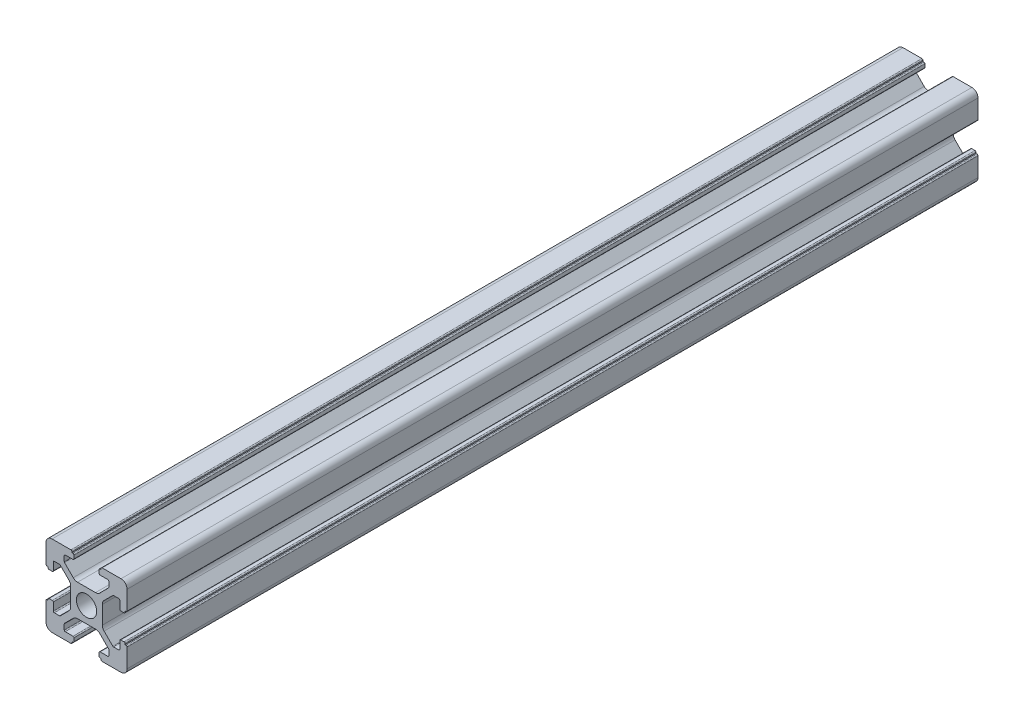
from build123d import *

# Parameters (mm, degrees)
SKETCH_1_R         = 2.5
EXTRUDE_1_DEPTH    = 1220
SKETCH1_R          = 16.771487081
CUT_EXTRUDE1_DEPTH = 1011


with BuildPart() as part:
    # 草图1 → 凸台-拉伸1 (new body)
    with BuildSketch(Plane.XY):
        with BuildLine():
            Line((-8.502261885, -10.002261885), (-3.85, -10.002261885))
            ThreePointArc((-3.85, -10.002261885), (-3.673223305, -9.929038581), (-3.6, -9.752261885))
            Line((-3.6, -9.752261885), (-3.6, -9.502261885))
            Line((-3.6, -9.502261885), (-3.35, -9.502261885))
            ThreePointArc((-3.35, -9.502261885), (-3.173223305, -9.429038581), (-3.1, -9.252261885))
            Line((-3.1, -9.252261885), (-3.1, -8.45))
            ThreePointArc((-3.1, -8.45), (-3.173223305, -8.273223305), (-3.35, -8.2))
            Line((-3.35, -8.2), (-5.25, -8.2))
            ThreePointArc((-5.25, -8.2), (-5.426776695, -8.126776695), (-5.5, -7.95))
            Line((-5.5, -7.95), (-5.5, -6.664213562))
            ThreePointArc((-5.5, -6.664213562), (-5.480969883, -6.568542704), (-5.426776695, -6.487436867))
            Line((-5.426776695, -6.487436867), (-3.278679656, -4.339339828))
            ThreePointArc((-3.278679656, -4.339339828), (-2.792044633, -4.014180701), (-2.218019485, -3.9))
            Line((-2.218019485, -3.9), (2.218019485, -3.9))
            ThreePointArc((2.218019485, -3.9), (2.792044633, -4.014180701), (3.278679656, -4.339339828))
            Line((3.278679656, -4.339339828), (5.426776695, -6.487436867))
            ThreePointArc((5.426776695, -6.487436867), (5.480969883, -6.568542704), (5.5, -6.664213562))
            Line((5.5, -6.664213562), (5.5, -7.95))
            ThreePointArc((5.5, -7.95), (5.426776695, -8.126776695), (5.25, -8.2))
            Line((5.25, -8.2), (3.35, -8.2))
            ThreePointArc((3.35, -8.2), (3.173223305, -8.273223305), (3.1, -8.45))
            Line((3.1, -8.45), (3.1, -9.252261885))
            ThreePointArc((3.1, -9.252261885), (3.173223305, -9.429038581), (3.35, -9.502261885))
            Line((3.35, -9.502261885), (3.6, -9.502261885))
            Line((3.6, -9.502261885), (3.6, -9.752261885))
            ThreePointArc((3.6, -9.752261885), (3.673223305, -9.929038581), (3.85, -10.002261885))
            Line((3.85, -10.002261885), (8.502261885, -10.002261885))
            ThreePointArc((8.502261885, -10.002261885), (9.562922057, -9.562922057), (10.002261885, -8.502261885))
            Line((10.002261885, -8.502261885), (10.002261885, -3.85))
            ThreePointArc((10.002261885, -3.85), (9.929038581, -3.673223305), (9.752261885, -3.6))
            Line((9.752261885, -3.6), (9.502261885, -3.6))
            Line((9.502261885, -3.6), (9.502261885, -3.35))
            ThreePointArc((9.502261885, -3.35), (9.429038581, -3.173223305), (9.252261885, -3.1))
            Line((9.252261885, -3.1), (8.45, -3.1))
            ThreePointArc((8.45, -3.1), (8.273223305, -3.173223305), (8.2, -3.35))
            Line((8.2, -3.35), (8.2, -5.25))
            ThreePointArc((8.2, -5.25), (8.126776695, -5.426776695), (7.95, -5.5))
            Line((7.95, -5.5), (6.664213562, -5.5))
            ThreePointArc((6.664213562, -5.5), (6.568542704, -5.480969883), (6.487436867, -5.426776695))
            Line((6.487436867, -5.426776695), (4.339339828, -3.278679656))
            ThreePointArc((4.339339828, -3.278679656), (4.014180701, -2.792044633), (3.9, -2.218019485))
            Line((3.9, -2.218019485), (3.9, 2.218019485))
            ThreePointArc((3.9, 2.218019485), (4.014180701, 2.792044633), (4.339339828, 3.278679656))
            Line((4.339339828, 3.278679656), (6.487436867, 5.426776695))
            ThreePointArc((6.487436867, 5.426776695), (6.568542704, 5.480969883), (6.664213562, 5.5))
            Line((6.664213562, 5.5), (7.95, 5.5))
            ThreePointArc((7.95, 5.5), (8.126776695, 5.426776695), (8.2, 5.25))
            Line((8.2, 5.25), (8.2, 3.35))
            ThreePointArc((8.2, 3.35), (8.273223305, 3.173223305), (8.45, 3.1))
            Line((8.45, 3.1), (9.252261885, 3.1))
            ThreePointArc((9.252261885, 3.1), (9.429038581, 3.173223305), (9.502261885, 3.35))
            Line((9.502261885, 3.35), (9.502261885, 3.6))
            Line((9.502261885, 3.6), (9.752261885, 3.6))
            ThreePointArc((9.752261885, 3.6), (9.929038581, 3.673223305), (10.002261885, 3.85))
            Line((10.002261885, 3.85), (10.002261885, 8.502261885))
            ThreePointArc((10.002261885, 8.502261885), (9.562922057, 9.562922057), (8.502261885, 10.002261885))
            Line((8.502261885, 10.002261885), (3.85, 10.002261885))
            ThreePointArc((3.85, 10.002261885), (3.673223305, 9.929038581), (3.6, 9.752261885))
            Line((3.6, 9.752261885), (3.6, 9.502261885))
            Line((3.6, 9.502261885), (3.35, 9.502261885))
            ThreePointArc((3.35, 9.502261885), (3.173223305, 9.429038581), (3.1, 9.252261885))
            Line((3.1, 9.252261885), (3.1, 8.45))
            ThreePointArc((3.1, 8.45), (3.173223305, 8.273223305), (3.35, 8.2))
            Line((3.35, 8.2), (5.25, 8.2))
            ThreePointArc((5.25, 8.2), (5.426776695, 8.126776695), (5.5, 7.95))
            Line((5.5, 7.95), (5.5, 6.664213562))
            ThreePointArc((5.5, 6.664213562), (5.480969883, 6.568542704), (5.426776695, 6.487436867))
            Line((5.426776695, 6.487436867), (3.278679656, 4.339339828))
            ThreePointArc((3.278679656, 4.339339828), (2.792044633, 4.014180701), (2.218019485, 3.9))
            Line((2.218019485, 3.9), (-2.218019485, 3.9))
            ThreePointArc((-2.218019485, 3.9), (-2.792044633, 4.014180701), (-3.278679656, 4.339339828))
            Line((-3.278679656, 4.339339828), (-5.426776695, 6.487436867))
            ThreePointArc((-5.426776695, 6.487436867), (-5.480969883, 6.568542704), (-5.5, 6.664213562))
            Line((-5.5, 6.664213562), (-5.5, 7.95))
            ThreePointArc((-5.5, 7.95), (-5.426776695, 8.126776695), (-5.25, 8.2))
            Line((-5.25, 8.2), (-3.35, 8.2))
            ThreePointArc((-3.35, 8.2), (-3.173223305, 8.273223305), (-3.1, 8.45))
            Line((-3.1, 8.45), (-3.1, 9.252261885))
            ThreePointArc((-3.1, 9.252261885), (-3.173223305, 9.429038581), (-3.35, 9.502261885))
            Line((-3.35, 9.502261885), (-3.6, 9.502261885))
            Line((-3.6, 9.502261885), (-3.6, 9.752261885))
            ThreePointArc((-3.6, 9.752261885), (-3.673223305, 9.929038581), (-3.85, 10.002261885))
            Line((-3.85, 10.002261885), (-8.502261885, 10.002261885))
            ThreePointArc((-8.502261885, 10.002261885), (-9.562922057, 9.562922057), (-10.002261885, 8.502261885))
            Line((-10.002261885, 8.502261885), (-10.002261885, 3.85))
            ThreePointArc((-10.002261885, 3.85), (-9.929038581, 3.673223305), (-9.752261885, 3.6))
            Line((-9.752261885, 3.6), (-9.502261885, 3.6))
            Line((-9.502261885, 3.6), (-9.502261885, 3.35))
            ThreePointArc((-9.502261885, 3.35), (-9.429038581, 3.173223305), (-9.252261885, 3.1))
            Line((-9.252261885, 3.1), (-8.45, 3.1))
            ThreePointArc((-8.45, 3.1), (-8.273223305, 3.173223305), (-8.2, 3.35))
            Line((-8.2, 3.35), (-8.2, 5.25))
            ThreePointArc((-8.2, 5.25), (-8.126776695, 5.426776695), (-7.95, 5.5))
            Line((-7.95, 5.5), (-6.664213562, 5.5))
            ThreePointArc((-6.664213562, 5.5), (-6.568542704, 5.480969883), (-6.487436867, 5.426776695))
            Line((-6.487436867, 5.426776695), (-4.339339828, 3.278679656))
            ThreePointArc((-4.339339828, 3.278679656), (-4.014180701, 2.792044633), (-3.9, 2.218019485))
            Line((-3.9, 2.218019485), (-3.9, -2.218019485))
            ThreePointArc((-3.9, -2.218019485), (-4.014180701, -2.792044633), (-4.339339828, -3.278679656))
            Line((-4.339339828, -3.278679656), (-6.487436867, -5.426776695))
            ThreePointArc((-6.487436867, -5.426776695), (-6.568542704, -5.480969883), (-6.664213562, -5.5))
            Line((-6.664213562, -5.5), (-7.95, -5.5))
            ThreePointArc((-7.95, -5.5), (-8.126776695, -5.426776695), (-8.2, -5.25))
            Line((-8.2, -5.25), (-8.2, -3.35))
            ThreePointArc((-8.2, -3.35), (-8.273223305, -3.173223305), (-8.45, -3.1))
            Line((-8.45, -3.1), (-9.252261885, -3.1))
            ThreePointArc((-9.252261885, -3.1), (-9.429038581, -3.173223305), (-9.502261885, -3.35))
            Line((-9.502261885, -3.35), (-9.502261885, -3.6))
            Line((-9.502261885, -3.6), (-9.752261885, -3.6))
            ThreePointArc((-9.752261885, -3.6), (-9.929038581, -3.673223305), (-10.002261885, -3.85))
            Line((-10.002261885, -3.85), (-10.002261885, -8.502261885))
            ThreePointArc((-10.002261885, -8.502261885), (-9.562922057, -9.562922057), (-8.502261885, -10.002261885))
        make_face()
        Circle(SKETCH_1_R, mode=Mode.SUBTRACT)
    extrude(amount=EXTRUDE_1_DEPTH)

    # Sketch1 → Cut-Extrude1 (cut, through all)
    with BuildSketch(Plane.XY.offset(1010)):
        Circle(SKETCH1_R)
    extrude(amount=-CUT_EXTRUDE1_DEPTH, mode=Mode.SUBTRACT)


solid = part.part
